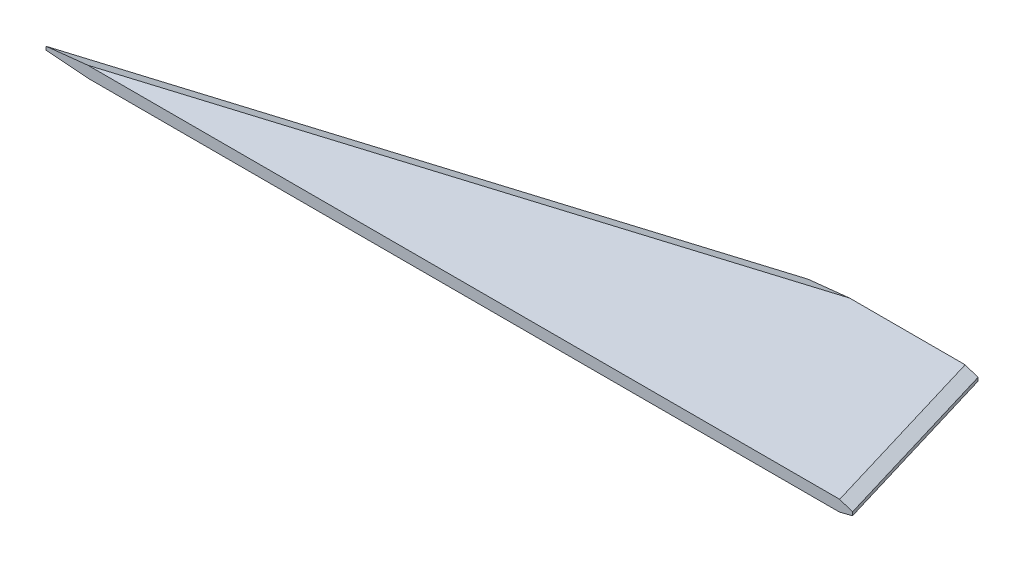
from build123d import *

# Parameters (mm, degrees)
BOSS_EXTRUDE1_DEPTH   = 3.175
CHAMFER1_SIZE         = 1.27
CHAMFER1_SIZE2        = 3.489296323
CHAMFER1_PART_2_SIZE  = 1.27
CHAMFER1_PART_2_SIZE2 = 3.489296323
CHAMFER2_SIZE         = 3.556
CHAMFER2_SIZE2        = 0.952827328


with BuildPart() as part:
    # Sketch1 → Boss-Extrude1 (new body)
    with BuildSketch(Plane(origin=(0, 0, 0), x_dir=(1, 0, 0), z_dir=(0, 1, 0))):
        Polygon((0, 0), (228.6, 0), (213.36, 50.8), (165.1, 50.8), align=None)
    extrude(amount=BOSS_EXTRUDE1_DEPTH)

    # Chamfer1
    chamfer1_edges = [part.edges().sort_by_distance(p)[0] for p in [
        (220.98, 3.175, -25.4),
    ]]
    chamfer1_side = [part.faces().sort_by_distance(p)[0] for p in [
        (220.98, 1.5875, -25.4),
    ]]
    chamfer(chamfer1_edges, length=CHAMFER1_SIZE, length2=CHAMFER1_SIZE2, reference=chamfer1_side[0])

    # Chamfer1 part 2
    chamfer1_part_2_edges = [part.edges().sort_by_distance(p)[0] for p in [
        (82.55, 3.175, -25.4),
    ]]
    chamfer1_part_2_side = [part.faces().sort_by_distance(p)[0] for p in [
        (82.55, 1.5875, -25.4),
    ]]
    chamfer(chamfer1_part_2_edges, length=CHAMFER1_PART_2_SIZE, length2=CHAMFER1_PART_2_SIZE2, reference=chamfer1_part_2_side[0])

    # Chamfer2
    chamfer2_edges = [part.edges().sort_by_distance(p)[0] for p in [
        (220.98, 0, -25.4),
        (82.55, 0, -25.4),
    ]]
    chamfer2_side = [part.faces().sort_by_distance(p)[0] for p in [
        (143.630397554, 0, -19.885015291),
    ]]
    chamfer(chamfer2_edges, length=CHAMFER2_SIZE, length2=CHAMFER2_SIZE2, reference=chamfer2_side[0])


solid = part.part
